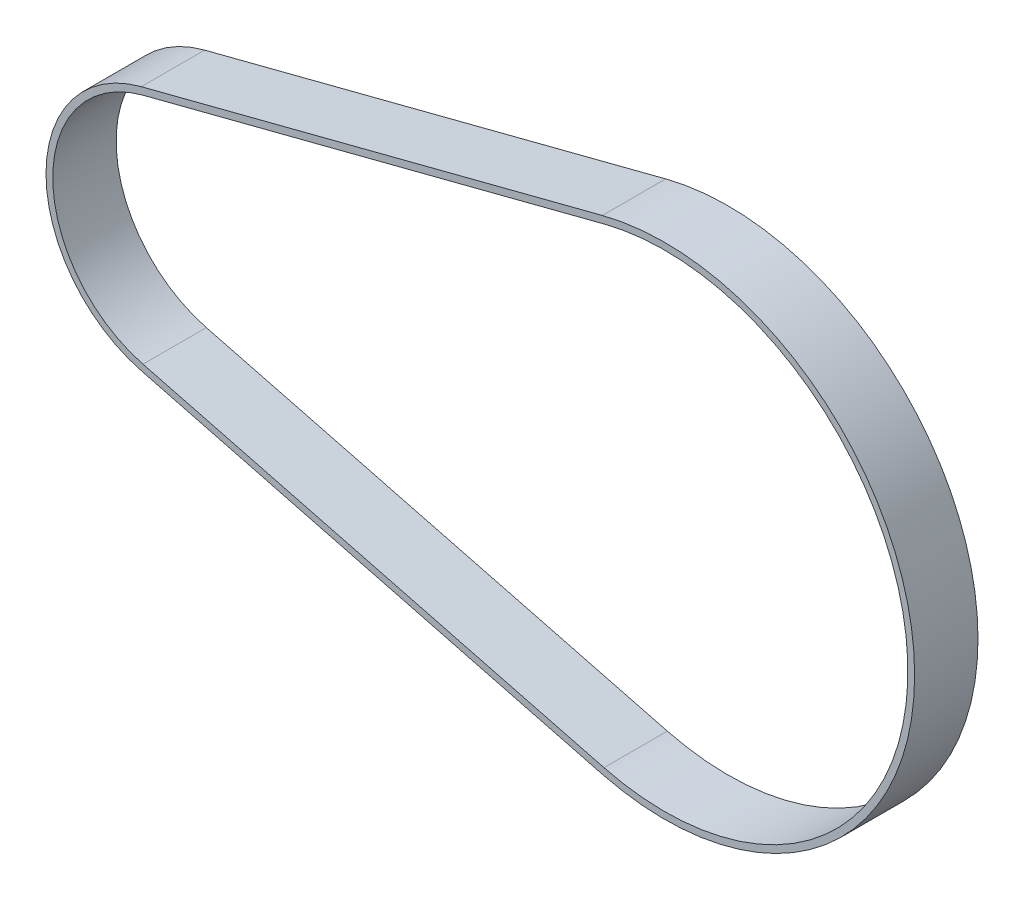
from build123d import *

# Parameters (mm, degrees)
BOSS_EXTRUDE1_DEPTH = 3


with BuildPart() as part:
    # Sketch4 → Boss-Extrude1 (new body, symmetric)
    with BuildSketch(Plane.XY):
        with BuildLine():
            Line((-49.569635322, 11.648391942), (-5.913243351, 22.914313825))
            ThreePointArc((-5.913243351, 22.914313825), (23.665, 0), (-5.913243351, -22.914313825))
            Line((-5.913243351, -22.914313825), (-49.569635322, -11.648391942))
            ThreePointArc((-49.569635322, -11.648391942), (-58.593663739, 0), (-49.569635322, 11.648391942))
        make_face()
        with BuildLine():
            Line((-49.409716634, 11.028693618), (-5.753324663, 22.294615501))
            ThreePointArc((-5.753324663, 22.294615501), (23.025, 0), (-5.753324663, -22.294615501))
            Line((-5.753324663, -22.294615501), (-49.409716634, -11.028693618))
            ThreePointArc((-49.409716634, -11.028693618), (-57.953663739, 0), (-49.409716634, 11.028693618))
        make_face(mode=Mode.SUBTRACT)
    extrude(amount=BOSS_EXTRUDE1_DEPTH, both=True)


solid = part.part
